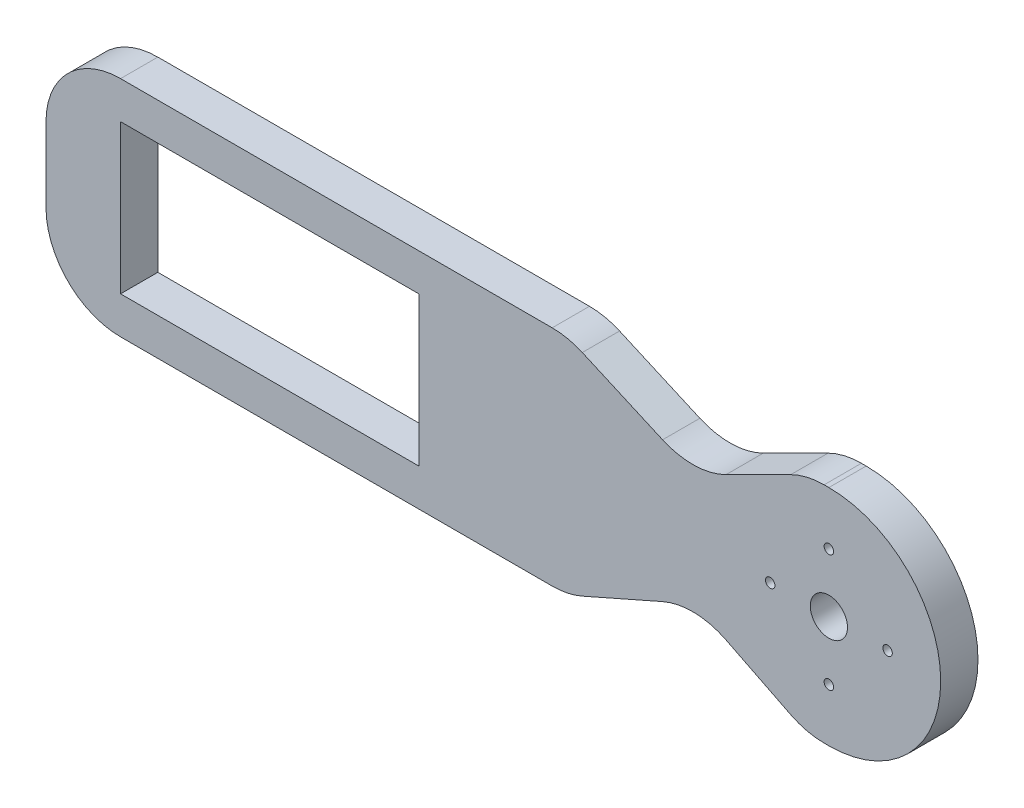
from build123d import *

# Parameters (mm, degrees)
SKETCH1_R           = 2.5
SKETCH1_R_2         = 0.635
SKETCH1_W           = 40
SKETCH1_H           = 20
BOSS_EXTRUDE1_DEPTH = 5
CUT_EXTRUDE1_DEPTH  = 5
FILLET1_R           = 10
FILLET2_R           = 10


with BuildPart() as part:
    # Sketch1 → Boss-Extrude1 (new body)
    with BuildSketch(Plane.XY):
        with BuildLine():
            Line((5, -0.042056462), (-100, -0.042056462))
            Line((-100, -0.042056462), (-100, 29.957943538))
            Line((-100, 29.957943538), (5, 29.957943538))
            ThreePointArc((5, 29.957943538), (20, 14.957943538), (5, -0.042056462))
        make_face()
        with Locations((5, 14.957943538)):
            Circle(SKETCH1_R, mode=Mode.SUBTRACT)
        with Locations((5, 22.832946838)):
            Circle(SKETCH1_R_2, mode=Mode.SUBTRACT)
        with Locations((-2.8750033, 14.957943538)):
            Circle(SKETCH1_R_2, mode=Mode.SUBTRACT)
        with Locations((12.8750033, 14.957943538)):
            Circle(SKETCH1_R_2, mode=Mode.SUBTRACT)
        with Locations((5, 7.082940238)):
            Circle(SKETCH1_R_2, mode=Mode.SUBTRACT)
        with Locations((-70, 14.957943538)):
            Rectangle(SKETCH1_W, SKETCH1_H, mode=Mode.SUBTRACT)
    extrude(amount=BOSS_EXTRUDE1_DEPTH)

    # Sketch2 → Cut-Extrude1 (cut)
    with BuildSketch(Plane.XY.offset(5)):
        with BuildLine():
            Line((-28.071470169, 29.107121554), (-17.302448086, 24.356082399))
            ThreePointArc((-17.302448086, 24.356082399), (-13.025291719, 23.508158967), (-8.793910065, 24.560988505))
            Line((-8.793910065, 24.560988505), (-0.11145618, 28.902215448))
            ThreePointArc((-0.11145618, 28.902215448), (2.06315057, 29.690433433), (4.360679775, 29.957943538))
            Line((4.360679775, 29.957943538), (-32.107872235, 29.957943538))
            ThreePointArc((-32.107872235, 29.957943538), (-30.04532286, 29.742926424), (-28.071470169, 29.107121554))
        make_face()
        with BuildLine():
            Line((-28.071470169, 0.808765522), (-17.302448086, 5.559804676))
            ThreePointArc((-17.302448086, 5.559804676), (-13.025291719, 6.407728109), (-8.793910065, 5.354898571))
            Line((-8.793910065, 5.354898571), (-0.11145618, 1.013671628))
            ThreePointArc((-0.11145618, 1.013671628), (2.06315057, 0.225453643), (4.360679775, -0.042056462))
            Line((4.360679775, -0.042056462), (-32.107872235, -0.042056462))
            ThreePointArc((-32.107872235, -0.042056462), (-30.04532286, 0.172960652), (-28.071470169, 0.808765522))
        make_face()
    extrude(amount=-CUT_EXTRUDE1_DEPTH, mode=Mode.SUBTRACT)

    # Fillet1
    fillet1_edges = [part.edges().sort_by_distance(p)[0] for p in [
        (-100, 29.957943538, 2.5),
    ]]
    fillet(fillet1_edges, radius=FILLET1_R)

    # Fillet2
    fillet2_edges = [part.edges().sort_by_distance(p)[0] for p in [
        (-100, -0.042056462, 2.5),
    ]]
    fillet(fillet2_edges, radius=FILLET2_R)


solid = part.part
